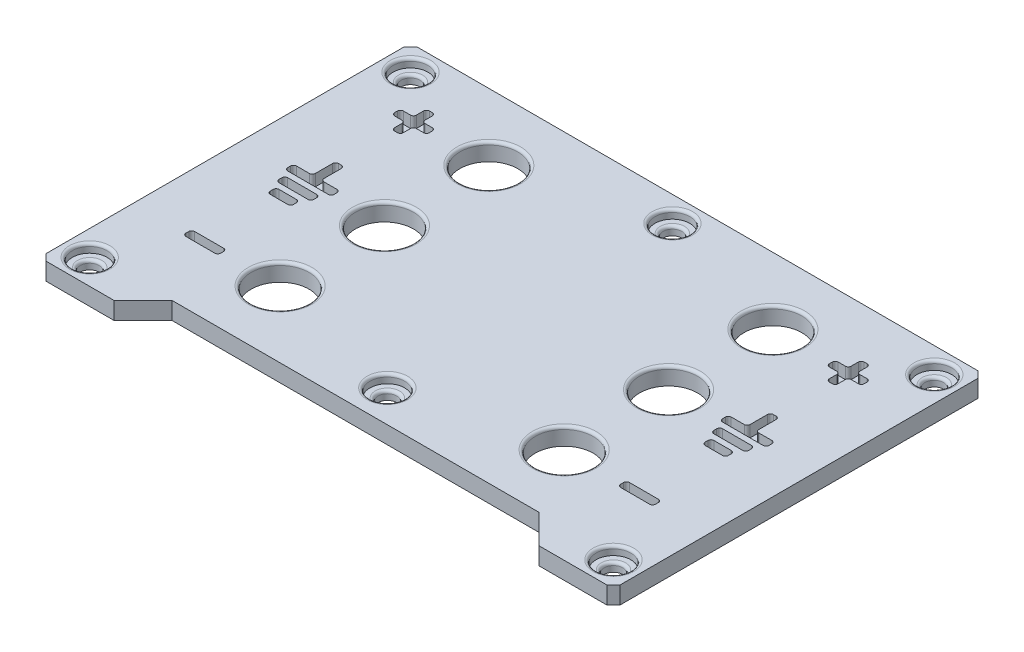
from build123d import *

# Parameters (mm, degrees)
SKETCH3_R           = 1.6
SKETCH3_R_2         = 5
BOSS_EXTRUDE1_DEPTH = 3
SKETCH4_R           = 3
CUT_EXTRUDE1_DEPTH  = 1.5
FILLET1_R           = 0.5
SKETCH5_W           = 6
SKETCH5_H           = 1.5
SKETCH5_W_2         = 4
CUT_EXTRUDE2_DEPTH  = 2
FILLET2_R           = 0.5


with BuildPart() as part:
    # Sketch3 → Boss-Extrude1 (new body)
    with BuildSketch(Plane(origin=(0, 0, 0), x_dir=(1, 0, 0), z_dir=(0, 1, 0))):
        Polygon((17.352282825, -19.043486229), (29.109642138, -19.043486229), (30.230962482, -17.922165885), (30.230962482, 43.835193428), (29.109642138, 44.956513771), (-67.647717175, 44.956513771), (-68.769037518, 43.835193428), (-68.769037518, -17.922165885), (-67.647717175, -19.043486229), (-55.890357862, -19.043486229), (-50.890357862, -14.043486229), (12.352282825, -14.043486229), align=None)
        with Locations((-64.439037518, 40.626513771)):
            Circle(SKETCH3_R, mode=Mode.SUBTRACT)
        with Locations((-64.439037518, -14.713486229)):
            Circle(SKETCH3_R, mode=Mode.SUBTRACT)
        with Locations((25.900962482, 40.626513771)):
            Circle(SKETCH3_R, mode=Mode.SUBTRACT)
        with Locations((25.900962482, -14.713486229)):
            Circle(SKETCH3_R, mode=Mode.SUBTRACT)
        with Locations((-43.769037518, 33.456513771)):
            Circle(SKETCH3_R_2, mode=Mode.SUBTRACT)
        with Locations((-43.769037518, 15.456513771)):
            Circle(SKETCH3_R_2, mode=Mode.SUBTRACT)
        with Locations((-43.769037518, -2.543486229)):
            Circle(SKETCH3_R_2, mode=Mode.SUBTRACT)
        with Locations((5.230962482, -2.543486229)):
            Circle(SKETCH3_R_2, mode=Mode.SUBTRACT)
        with Locations((5.230962482, 15.456513771)):
            Circle(SKETCH3_R_2, mode=Mode.SUBTRACT)
        with Locations((5.230962482, 33.456513771)):
            Circle(SKETCH3_R_2, mode=Mode.SUBTRACT)
        with Locations((-19.269037518, 40.626513771)):
            Circle(SKETCH3_R, mode=Mode.SUBTRACT)
        with Locations((-19.269037518, -8.543486229)):
            Circle(SKETCH3_R, mode=Mode.SUBTRACT)
    extrude(amount=-BOSS_EXTRUDE1_DEPTH)

    # Sketch4 → Cut-Extrude1 (cut)
    with BuildSketch(Plane(origin=(0, 0, 0), x_dir=(1, 0, 0), z_dir=(0, 1, 0))):
        with Locations((-64.439037518, 40.626513771)):
            Circle(SKETCH4_R)
        with Locations((-64.439037518, -14.713486229)):
            Circle(SKETCH4_R)
        with Locations((25.900962482, 40.626513771)):
            Circle(SKETCH4_R)
        with Locations((25.900962482, -14.713486229)):
            Circle(SKETCH4_R)
        with Locations((-19.269037518, 40.626513771)):
            Circle(SKETCH4_R)
        with Locations((-19.269037518, -8.543486229)):
            Circle(SKETCH4_R)
    extrude(amount=-CUT_EXTRUDE1_DEPTH, mode=Mode.SUBTRACT)

    # Fillet1
    fillet1_edges = [part.edges().sort_by_distance(p)[0] for p in [
        (-67.439037518, 0, 14.713486229),
        (-66.039037518, -1.5, 14.713486229),
        (-22.269037518, 0, 8.543486229),
        (-20.869037518, -1.5, 8.543486229),
        (-67.439037518, 0, -40.626513771),
        (-66.039037518, -1.5, -40.626513771),
        (-48.769037518, 0, -33.456513771),
        (-48.769037518, 0, -15.456513771),
        (-48.769037518, 0, 2.543486229),
        (0.230962482, 0, 2.543486229),
        (0.230962482, 0, -15.456513771),
        (0.230962482, 0, -33.456513771),
        (-22.269037518, 0, -40.626513771),
        (-20.869037518, -1.5, -40.626513771),
        (22.900962482, 0, 14.713486229),
        (24.300962482, -1.5, 14.713486229),
        (22.900962482, 0, -40.626513771),
        (24.300962482, -1.5, -40.626513771),
    ]]
    fillet(fillet1_edges, radius=FILLET1_R)

    # Sketch5 → Cut-Extrude2 (cut)
    with BuildSketch(Plane(origin=(0, 0, 0), x_dir=(1, 0, 0), z_dir=(0, 1, 0))):
        Polygon((-57.519037518, 30.456513771), (-56.019037518, 30.456513771), (-56.019037518, 32.706513771), (-53.769037518, 32.706513771), (-53.769037518, 34.206513771), (-56.019037518, 34.206513771), (-56.019037518, 36.456513771), (-57.519037518, 36.456513771), (-57.519037518, 34.206513771), (-59.769037518, 34.206513771), (-59.769037518, 32.706513771), (-57.519037518, 32.706513771), align=None)
        Polygon((-56.019037518, 16.770918537), (-52.769037518, 16.770918537), (-52.769037518, 15.270918537), (-60.769037518, 15.270918537), (-60.769037518, 16.770918537), (-57.519037518, 16.770918537), (-57.519037518, 20.770918537), (-56.019037518, 20.770918537), align=None)
        with Locations((-56.769037518, -2.543486229)):
            Rectangle(SKETCH5_W, SKETCH5_H)
        with Locations((-56.769037518, 13.520918537)):
            Rectangle(SKETCH5_W, SKETCH5_H)
        with Locations((-56.769037518, 11.020918537)):
            Rectangle(SKETCH5_W_2, SKETCH5_H)
    cut_extrude2 = extrude(amount=-CUT_EXTRUDE2_DEPTH, mode=Mode.SUBTRACT)

    # Mirror1: Cut-Extrude2 across plane
    add(cut_extrude2.mirror(Plane.ZY.offset(19.269037518)), mode=Mode.SUBTRACT)

    # Fillet2
    fillet2_edges = [part.edges().sort_by_distance(p)[0] for p in [
        (-56.019037518, -1, -36.456513771),
        (-56.019037518, -1, -34.206513771),
        (-53.769037518, -1, -34.206513771),
        (-53.769037518, -1, -32.706513771),
        (-56.019037518, -1, -32.706513771),
        (-56.019037518, -1, -30.456513771),
        (-57.519037518, -1, -30.456513771),
        (-57.519037518, -1, -32.706513771),
        (-59.769037518, -1, -32.706513771),
        (-59.769037518, -1, -34.206513771),
        (-57.519037518, -1, -34.206513771),
        (-57.519037518, -1, -36.456513771),
        (-53.769037518, -1, -14.270918537),
        (-53.769037518, -1, -12.770918537),
        (-59.769037518, -1, -12.770918537),
        (-59.769037518, -1, -14.270918537),
        (-54.769037518, -1, -11.770918537),
        (-54.769037518, -1, -10.270918537),
        (-58.769037518, -1, -10.270918537),
        (-58.769037518, -1, -11.770918537),
        (-56.019037518, -1, -20.770918537),
        (-56.019037518, -1, -16.770918537),
        (-52.769037518, -1, -16.770918537),
        (-52.769037518, -1, -15.270918537),
        (-60.769037518, -1, -15.270918537),
        (-60.769037518, -1, -16.770918537),
        (-57.519037518, -1, -16.770918537),
        (-57.519037518, -1, -20.770918537),
        (-53.769037518, -1, 1.793486229),
        (-53.769037518, -1, 3.293486229),
        (-59.769037518, -1, 3.293486229),
        (-59.769037518, -1, 1.793486229),
        (17.480962482, -1, -34.206513771),
        (17.480962482, -1, -36.456513771),
        (18.980962482, -1, -36.456513771),
        (18.980962482, -1, -34.206513771),
        (21.230962482, -1, -34.206513771),
        (21.230962482, -1, -32.706513771),
        (18.980962482, -1, -32.706513771),
        (18.980962482, -1, -30.456513771),
        (17.480962482, -1, -30.456513771),
        (17.480962482, -1, -32.706513771),
        (15.230962482, -1, -32.706513771),
        (15.230962482, -1, -34.206513771),
        (15.230962482, -1, -12.770918537),
        (15.230962482, -1, -14.270918537),
        (21.230962482, -1, -14.270918537),
        (21.230962482, -1, -12.770918537),
        (16.230962482, -1, -10.270918537),
        (16.230962482, -1, -11.770918537),
        (20.230962482, -1, -11.770918537),
        (20.230962482, -1, -10.270918537),
        (17.480962482, -1, -16.770918537),
        (17.480962482, -1, -20.770918537),
        (18.980962482, -1, -20.770918537),
        (18.980962482, -1, -16.770918537),
        (22.230962482, -1, -16.770918537),
        (22.230962482, -1, -15.270918537),
        (14.230962482, -1, -15.270918537),
        (14.230962482, -1, -16.770918537),
        (15.230962482, -1, 3.293486229),
        (15.230962482, -1, 1.793486229),
        (21.230962482, -1, 1.793486229),
        (21.230962482, -1, 3.293486229),
    ]]
    fillet(fillet2_edges, radius=FILLET2_R)


solid = part.part
